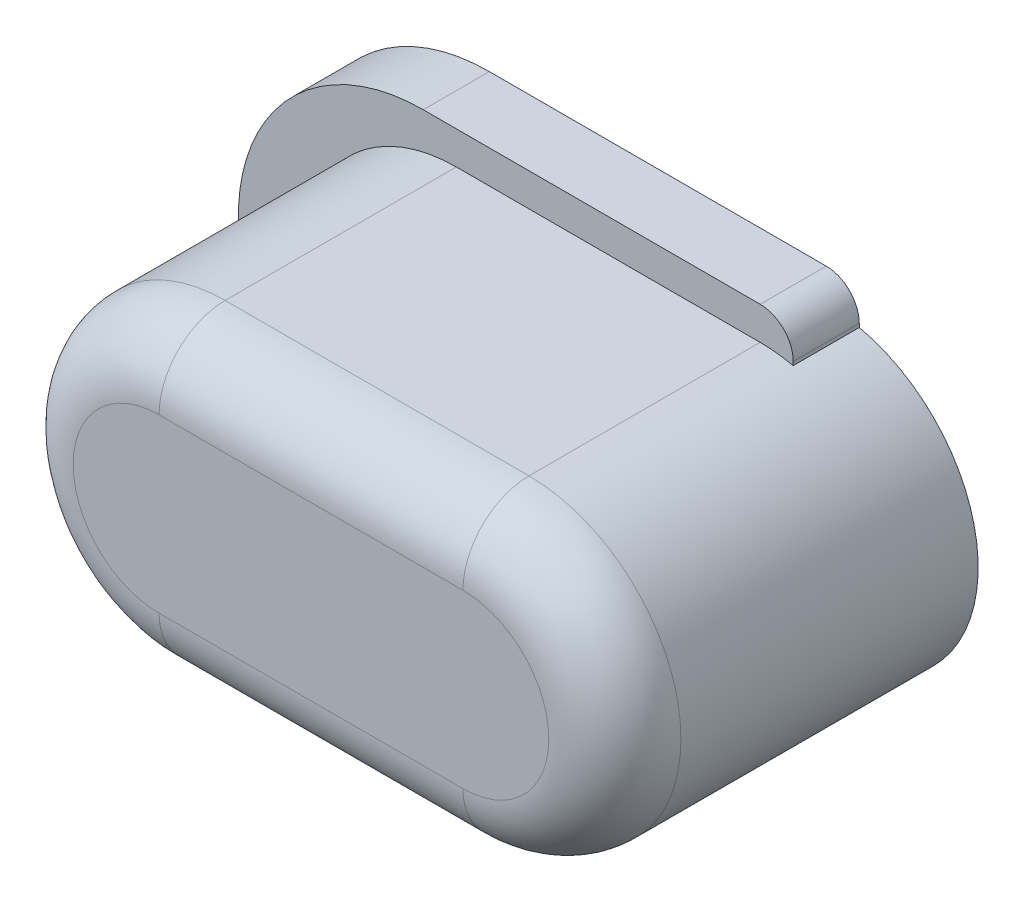
from build123d import *

# Parameters (mm, degrees)
EXTRUDE_1_DEPTH     = 5.5
EXTRUDE_2_DEPTH     = 1
SKETCH_3_R          = 2
CUT_EXTRUDE_1_DEPTH = 0.5
FILLET_1_R          = 1


with BuildPart() as part:
    # 草图1 → 凸台-拉伸1 (new body)
    with BuildSketch(Plane.XY):
        with BuildLine():
            Line((2.3, -2.3), (-2.3, -2.3))
            ThreePointArc((-2.3, -2.3), (-4.6, 0), (-2.3, 2.3))
            Line((-2.3, 2.3), (2.3, 2.3))
            ThreePointArc((2.3, 2.3), (4.6, 0), (2.3, -2.3))
        make_face()
    extrude(amount=EXTRUDE_1_DEPTH)

    # 草图2 → 凸台-拉伸2 (add)
    with BuildSketch(Plane(origin=(0, 0, 0), x_dir=(-1, 0, 0), z_dir=(0, 0, -1))):
        with BuildLine():
            Line((2.8, -2.8), (-2.3, -2.8))
            ThreePointArc((-2.3, -2.8), (-2.653553391, -2.653553391), (-2.8, -2.3))
            Line((-2.8, -2.3), (-2.8, 2.3))
            ThreePointArc((-2.8, 2.3), (-2.653553391, 2.653553391), (-2.3, 2.8))
            Line((-2.3, 2.8), (2.8, 2.8))
            ThreePointArc((2.8, 2.8), (5.6, 0), (2.8, -2.8))
        make_face()
    extrude(amount=-EXTRUDE_2_DEPTH)

    # 草图3 → 切除-拉伸1 (cut)
    with BuildSketch(Plane(origin=(0, 0, 0), x_dir=(-1, 0, 0), z_dir=(0, 0, -1))):
        Circle(SKETCH_3_R)
    extrude(amount=-CUT_EXTRUDE_1_DEPTH, mode=Mode.SUBTRACT)

    # 圆角1
    fillet_1_edges = [part.edges().sort_by_distance(p)[0] for p in [
        (-4.6, 0, 5.5),
        (0, -2.3, 5.5),
        (4.6, 0, 5.5),
        (0, 2.3, 5.5),
    ]]
    fillet(fillet_1_edges, radius=FILLET_1_R)


solid = part.part
